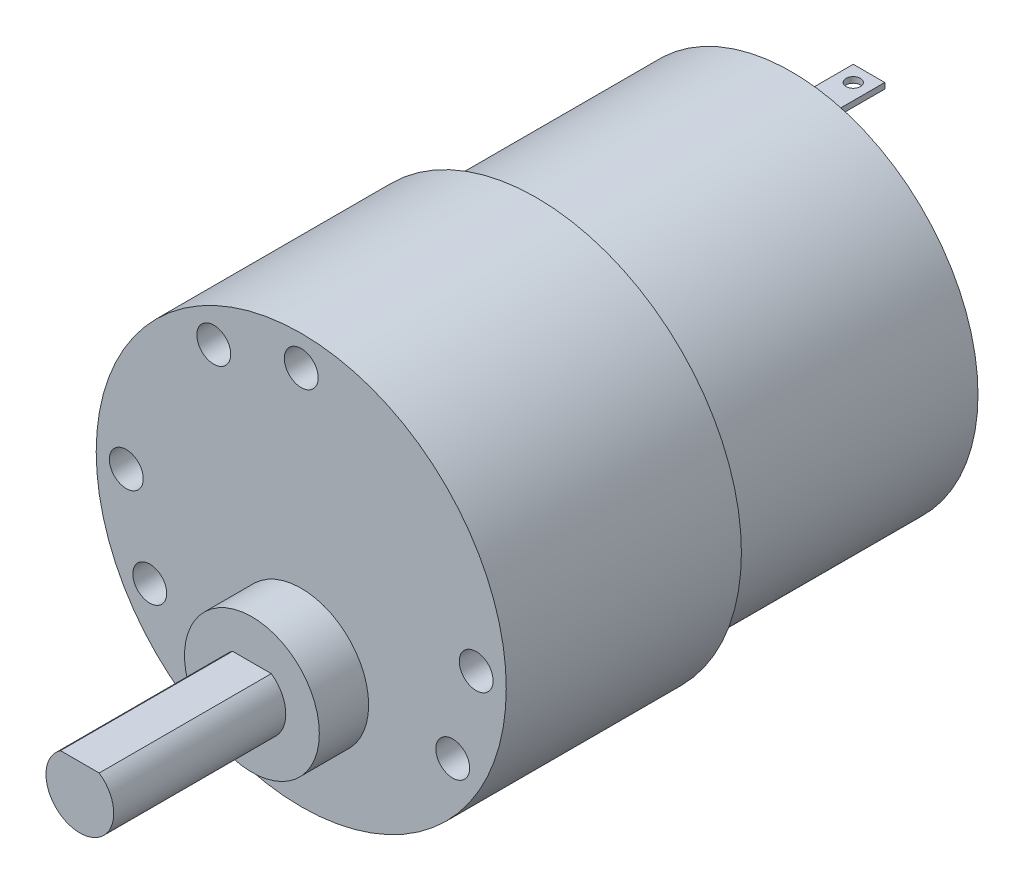
from build123d import *

# Parameters (mm, degrees)
SKETCH1_R           = 18.161
BOSS_EXTRUDE1_DEPTH = 20.828
SKETCH2_R           = 16.51
BOSS_EXTRUDE2_DEPTH = 22.606
SKETCH3_R           = 4.5085
BOSS_EXTRUDE3_DEPTH = 3.302
SKETCH4_R           = 2.413
BOSS_EXTRUDE4_DEPTH = 1.27
SKETCH5_R           = 5.969
BOSS_EXTRUDE5_DEPTH = 4.3688
BOSS_EXTRUDE6_DEPTH = 15.24
SKETCH8_W           = 5.588
SKETCH8_H           = 2.794
SKETCH8_R           = 0.635
BOSS_EXTRUDE7_DEPTH = 0.254
CIRPATTERN1_COUNT   = 2
CIRPATTERN2_COUNT   = 12


with BuildPart() as part:
    # Sketch1 → Boss-Extrude1 (new body)
    with BuildSketch(Plane.XY):
        Circle(SKETCH1_R)
    extrude(amount=BOSS_EXTRUDE1_DEPTH)

    # Sketch2 → Boss-Extrude2 (add)
    with BuildSketch(Plane(origin=(0, 0, 0), x_dir=(-1, 0, 0), z_dir=(0, 0, -1))):
        Circle(SKETCH2_R)
    extrude(amount=BOSS_EXTRUDE2_DEPTH)

    # Sketch3 → Boss-Extrude3 (add)
    with BuildSketch(Plane(origin=(0, 0, -22.606), x_dir=(-1, 0, 0), z_dir=(0, 0, -1))):
        Circle(SKETCH3_R)
    extrude(amount=BOSS_EXTRUDE3_DEPTH)

    # Sketch4 → Boss-Extrude4 (add)
    with BuildSketch(Plane(origin=(0, 0, -22.606), x_dir=(-1, 0, 0), z_dir=(0, 0, -1))):
        with Locations((0, -12.7)):
            Circle(SKETCH4_R)
        with Locations((0, 12.7)):
            Circle(SKETCH4_R)
    extrude(amount=BOSS_EXTRUDE4_DEPTH)

    # Sketch5 → Boss-Extrude5 (add)
    with BuildSketch(Plane.XY.offset(20.828)):
        with Locations((0, -7.366)):
            Circle(SKETCH5_R)
    extrude(amount=BOSS_EXTRUDE5_DEPTH)

    # Sketch6 → Boss-Extrude6 (add)
    with BuildSketch(Plane.XY.offset(25.1968)):
        with BuildLine():
            Line((-1.715657017, -4.905), (1.715657017, -4.905))
            ThreePointArc((1.715657017, -4.905), (0, -10.366), (-1.715657017, -4.905))
        make_face()
    extrude(amount=BOSS_EXTRUDE6_DEPTH)

    # Sketch8 → Boss-Extrude7 (add, symmetric)
    with BuildSketch(Plane.ZX.offset(12.7)):
        with Locations((-26.67, 0)):
            Rectangle(SKETCH8_W, SKETCH8_H)
        with Locations((-28.067, 0)):
            Circle(SKETCH8_R, mode=Mode.SUBTRACT)
    boss_extrude7 = extrude(amount=BOSS_EXTRUDE7_DEPTH, both=True)

    # CirPattern1: Boss-Extrude7 ×2 about axis
    cirpattern1_axis = Axis((0, 0, -25.908), (0, 0, 1))
    for i in range(1, CIRPATTERN1_COUNT):
        add(boss_extrude7.rotate(cirpattern1_axis, i * 360 / CIRPATTERN1_COUNT))

    # Sketch12 → Ø3.0mm Dowel Hole1 (revolve, cut)
    with BuildSketch(Plane(origin=(0, 15.494, 20.828), x_dir=(0, -1, 0), z_dir=(1, 0, 0))):
        Polygon((0, 0), (0, 11.061290929), (1.5, 10.16), (1.5, 0), align=None)
    f_3_0mm_dowel_hole1 = revolve(axis=Axis((0, 15.494, 27.178), (0, 0, -1)), mode=Mode.SUBTRACT)

    # CirPattern2: Ø3.0mm Dowel Hole1 ×12 about axis, 5 skipped
    cirpattern2_axis = Axis((0, 0, 20.828), (0, 0, -1))
    add([f_3_0mm_dowel_hole1.rotate(cirpattern2_axis, i * 360 / CIRPATTERN2_COUNT) for i in range(1, CIRPATTERN2_COUNT) if i not in (1, 2, 5, 6, 10)], mode=Mode.SUBTRACT)


solid = part.part
